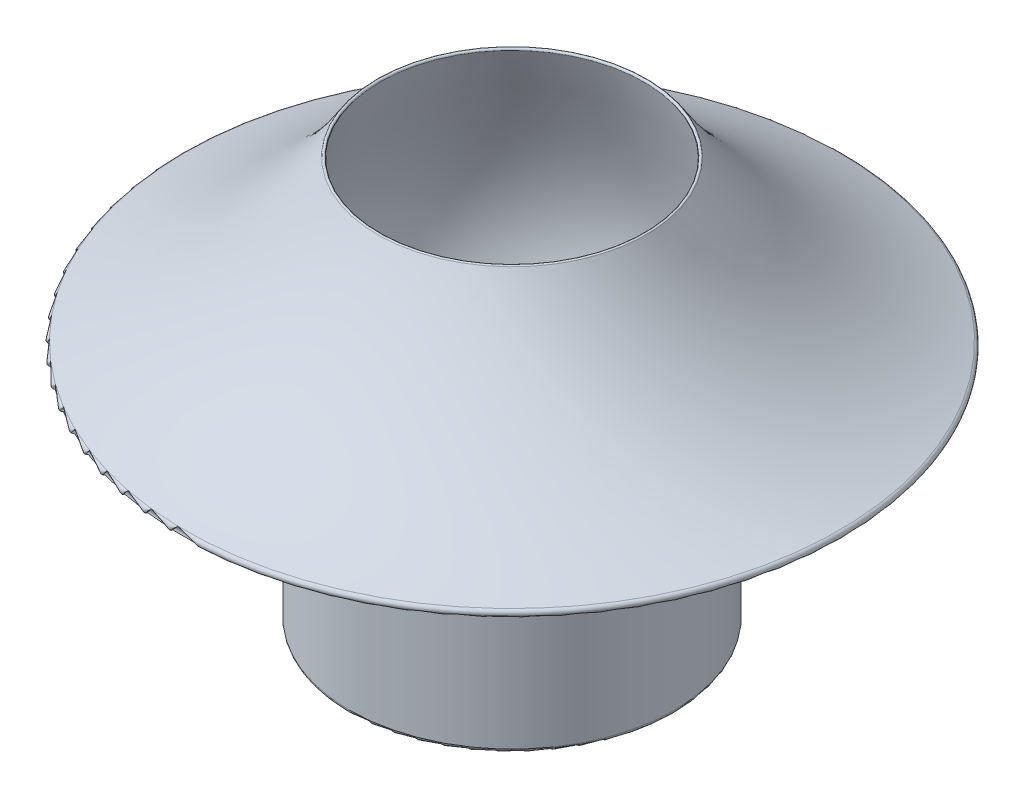
from build123d import *

# Parameters (mm, degrees)
FILLET1_R = 0.1
FILLET2_R = 0.25


with BuildPart() as part:
    # Sketch1 → Revolve2 (revolve)
    with BuildSketch(Plane.XY):
        with BuildLine():
            Line((-9.4, 0), (-10.7, 0))
            Line((-10.7, 0), (-10.7, 10.6))
            Line((-10.7, 10.6), (-14.8, 10.6))
            Line((-14.8, 10.6), (-14.8, 15.5))
            Line((-14.8, 15.5), (-23, 15.5))
            ThreePointArc((-23, 15.5), (-14.629240774, 19.96102489), (-8.5, 27.2))
            add(Edge.make_bspline(
                [(-8.5, 27.2), (-9.681332084, 22.731098706), (-12.794383887, 16.59065999), (-9.38266004, 9.934843606), (-9.332385206, 5.662057956), (-9.339485972, 4.846577744), (-9.4, 0)],
                knots=[0, 0, 0, 0, 0.480202228, 0.608836997, 0.660816774, 1, 1, 1, 1], degree=3))
        make_face()
    revolve(axis=Axis((0, 27.2, 0), (0, -1, 0)))

    # Fillet1
    fillet1_edges = [part.edges().sort_by_distance(p)[0] for p in [
        (8.5, 27.2, 0),
    ]]
    fillet(fillet1_edges, radius=FILLET1_R)

    # Fillet2
    fillet2_edges = [part.edges().sort_by_distance(p)[0] for p in [
        (10.7, 0, 0),
        (14.8, 10.6, 0),
        (23, 15.5, 0),
    ]]
    fillet(fillet2_edges, radius=FILLET2_R)


solid = part.part
